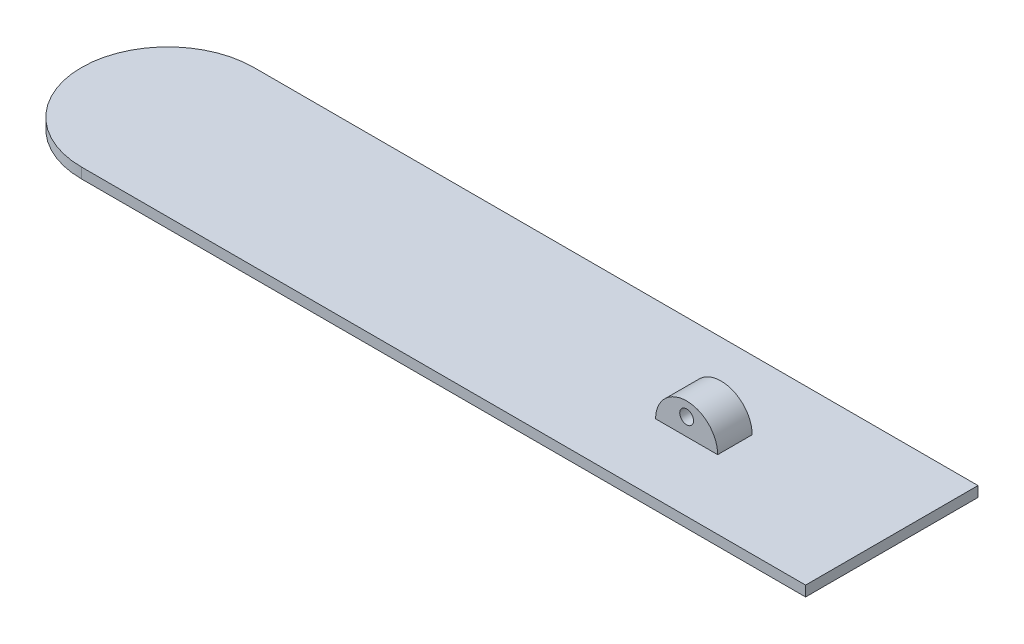
from build123d import *

# Parameters (mm, degrees)
BOSS_EXTRUDE1_DEPTH = 3
SKETCH3_R           = 2
BOSS_EXTRUDE2_DEPTH = 5


with BuildPart() as part:
    # Sketch1 → Boss-Extrude1 (new body)
    with BuildSketch(Plane(origin=(0, 0, 0), x_dir=(1, 0, 0), z_dir=(0, 1, 0))):
        with BuildLine():
            Line((0, 0), (210, 0))
            Line((210, 0), (210, 50))
            Line((210, 50), (0, 50))
            ThreePointArc((0, 50), (-25, 25), (0, 0))
        make_face()
    extrude(amount=BOSS_EXTRUDE1_DEPTH)

    # Sketch3 → Boss-Extrude2 (add, symmetric)
    with BuildSketch(Plane.XY.offset(-25)):
        with BuildLine():
            Line((146.5, 3), (164.5, 3))
            ThreePointArc((164.5, 3), (155.5, 12), (146.5, 3))
        make_face()
        with Locations((155.5, 8)):
            Circle(SKETCH3_R, mode=Mode.SUBTRACT)
    extrude(amount=BOSS_EXTRUDE2_DEPTH, both=True)


solid = part.part
